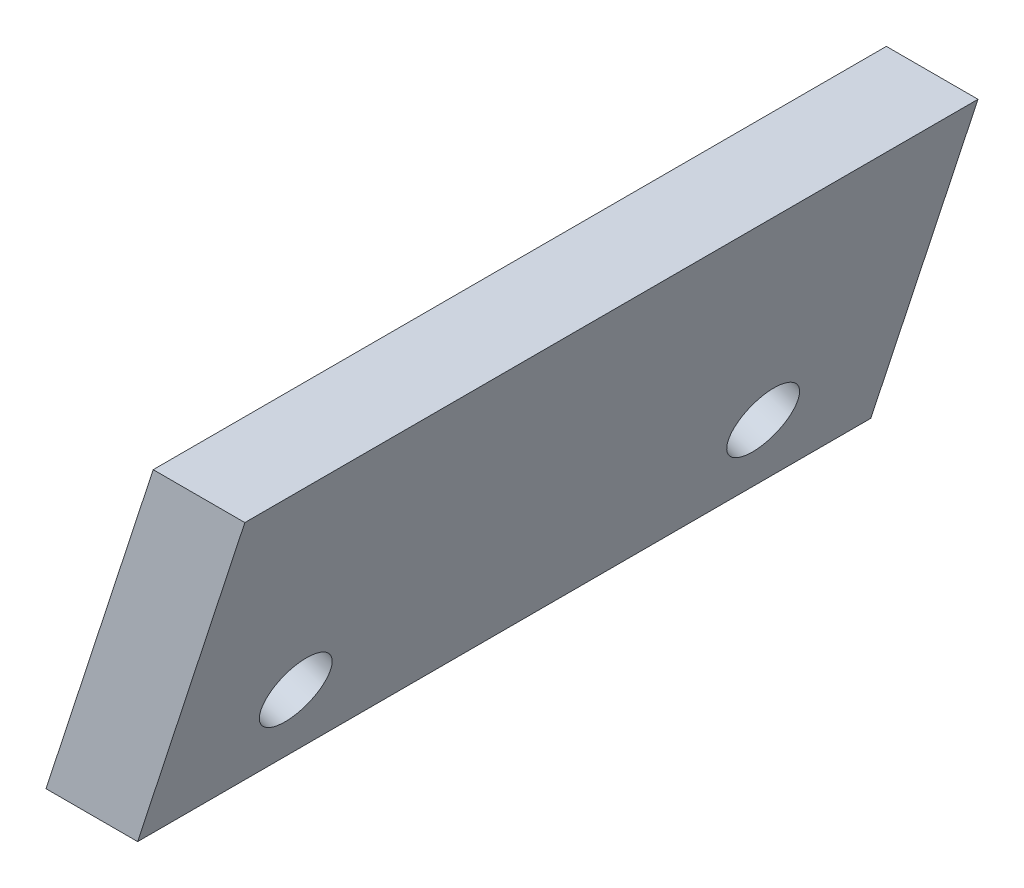
from build123d import *

# Parameters (mm, degrees)
BOSS_EXTRUDE2_DEPTH = 20
SKETCH4_R           = 0.95
CUT_EXTRUDE1_DEPTH  = 6.15879424


with BuildPart() as part:
    # Sketch2 → Boss-Extrude2 (new body)
    with BuildSketch(Plane.XY):
        Polygon((0, 0), (2.5, 0), (5.424277266, 9), (2.924277266, 9), align=None)
    extrude(amount=BOSS_EXTRUDE2_DEPTH)

    # Sketch4 → Cut-Extrude1 (cut, through all)
    with BuildSketch(Plane(origin=(0, 0, 0), x_dir=(0, 0, 1), z_dir=(-0.951056516, 0.309016994, 0))):
        with Locations((3.625, 3)):
            Circle(SKETCH4_R)
        with Locations((16.375, 3)):
            Circle(SKETCH4_R)
    extrude(amount=-CUT_EXTRUDE1_DEPTH, mode=Mode.SUBTRACT)


solid = part.part
